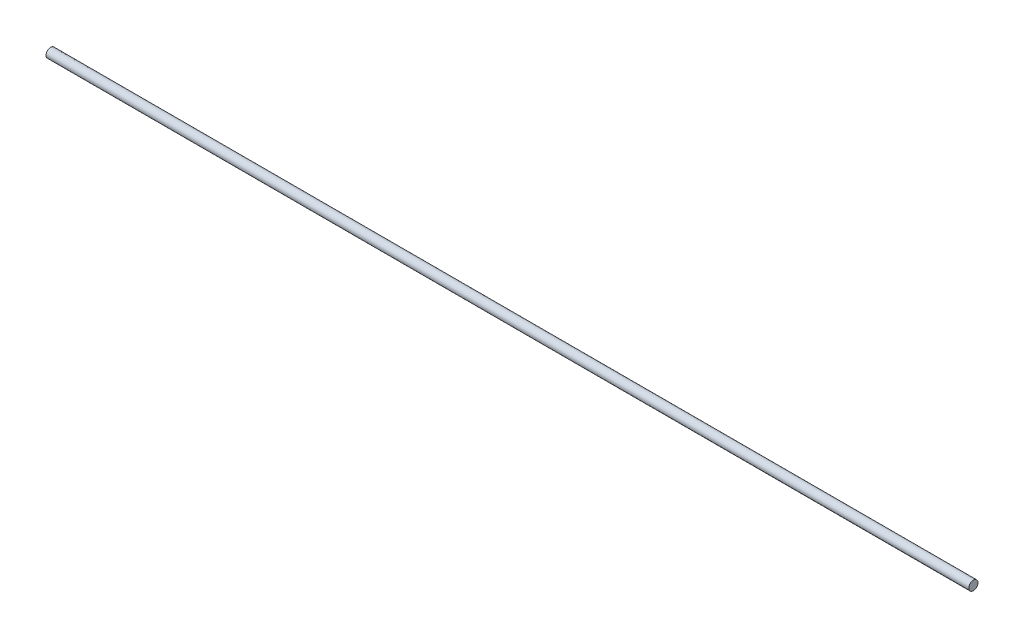
from build123d import *

# Parameters (mm, degrees)
CROQUIS1_R              = 4
SALIENTE_EXTRUIR1_DEPTH = 800


with BuildPart() as part:
    # Croquis1 → Saliente-Extruir1 (new body)
    with BuildSketch(Plane(origin=(0, 0, 0), x_dir=(0, 0, -1), z_dir=(1, 0, 0))):
        Circle(CROQUIS1_R)
    extrude(amount=SALIENTE_EXTRUIR1_DEPTH)


solid = part.part
